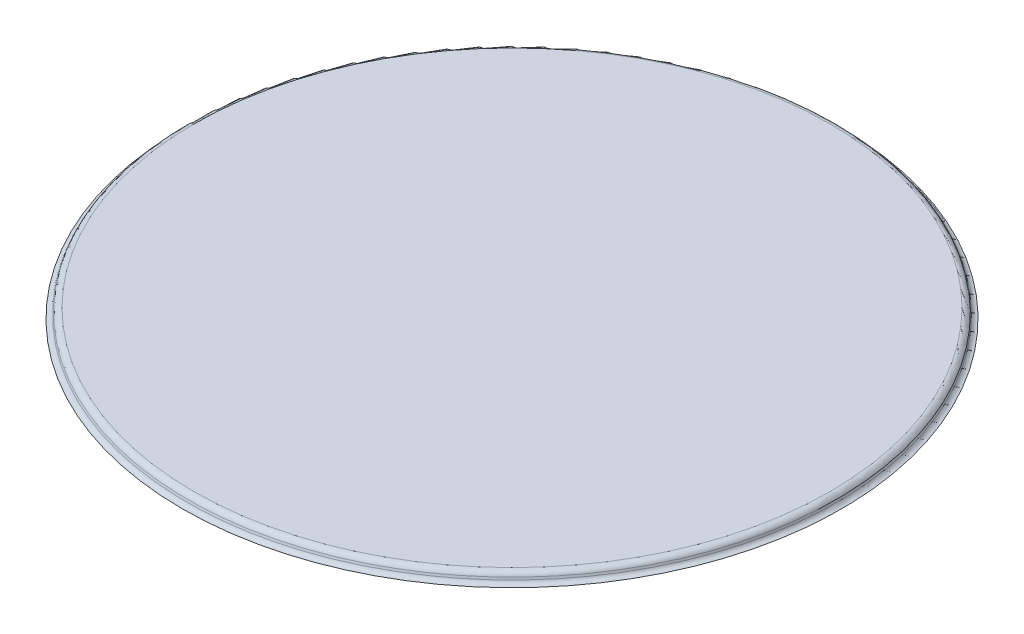
from build123d import *

# Parameters (mm, degrees)
SKIZZE1_R                       = 75
AUFSATZ_LINEAR_AUSTRAGEN1_DEPTH = 10
SKIZZE8_R                       = 75
SCHNITT_LINEAR_AUSTRAGEN1_DEPTH = 10


with BuildPart() as part:
    # Skizze1 → Aufsatz-Linear austragen1 (new body)
    with BuildSketch(Plane(origin=(0, 0, 0), x_dir=(1, 0, 0), z_dir=(0, 1, 0))):
        with Locations(Location((0, 0, 0), (0, 0, 270))):  # turned: the seam where the file's is
            Circle(SKIZZE1_R)
    extrude(amount=AUFSATZ_LINEAR_AUSTRAGEN1_DEPTH)

    # Skizze7 → Rotation1 (revolve)
    with BuildSketch(Plane.XY, mode=Mode.PRIVATE) as rotation1_sk:
        with BuildLine():
            Line((-51.748245903, 10.526383885), (-51.633363701, 10.842020143))
            ThreePointArc((-51.633363701, 10.842020143), (-51.267247516, 11.319152044), (-50.69367108, 11.5))
            Line((-50.69367108, 11.5), (0, 11.5))
            Line((0, 11.5), (0, 10))
            Line((0, 10), (-52.5, 10))
            ThreePointArc((-52.5, 10), (-52.041138851, 10.144678365), (-51.748245903, 10.526383885))
        make_face()
    revolve(rotation1_sk.sketch.rotate(Axis((0, 0, 0), (0, 1, 0)), 270), axis=Axis((0, 0, 0), (0, 1, 0)))  # turned: the seam where the file's is

    # Skizze8 → Schnitt-Linear austragen1 (cut)
    with BuildSketch(Plane.XZ):
        Circle(SKIZZE8_R)
    extrude(amount=-SCHNITT_LINEAR_AUSTRAGEN1_DEPTH, mode=Mode.SUBTRACT)


solid = part.part
